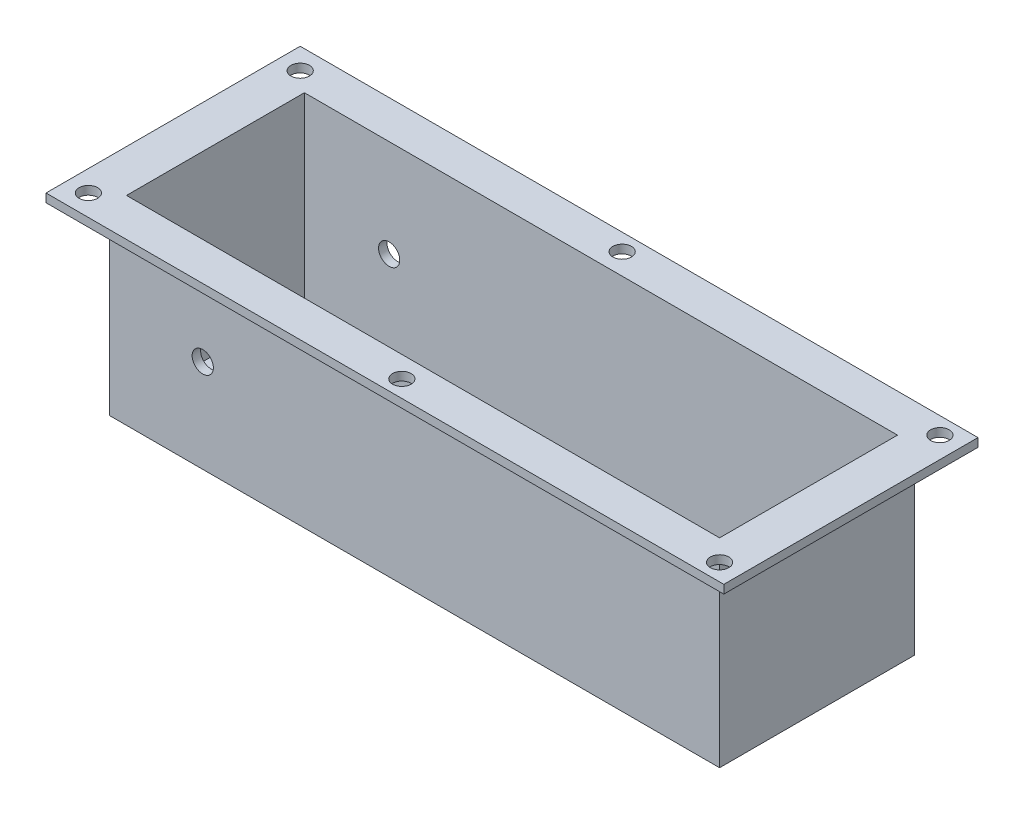
from build123d import *

# Parameters (mm, degrees)
SKETCH3_W           = 182.88
SKETCH3_H           = 58.42
BOSS_EXTRUDE1_DEPTH = 57.15
SKETCH4_W           = 203.2
SKETCH4_H           = 76.2
BOSS_EXTRUDE2_DEPTH = 2.54
SKETCH5_W           = 177.8
SKETCH5_H           = 53.34
CUT_EXTRUDE1_DEPTH  = 54.61
SKETCH6_R           = 2.7813
CUT_EXTRUDE2_DEPTH  = 53.34
SKETCH8_R           = 3.18135
CUT_EXTRUDE3_DEPTH  = 38.1


with BuildPart() as part:
    # Sketch3 → Boss-Extrude1 (new body)
    with BuildSketch(Plane(origin=(0, 0, 0), x_dir=(1, 0, 0), z_dir=(0, 1, 0))):
        Rectangle(SKETCH3_W, SKETCH3_H)
    extrude(amount=-BOSS_EXTRUDE1_DEPTH)

    # Sketch4 → Boss-Extrude2 (add)
    with BuildSketch(Plane(origin=(0, 0, 0), x_dir=(1, 0, 0), z_dir=(0, 1, 0))):
        Rectangle(SKETCH4_W, SKETCH4_H)
    extrude(amount=-BOSS_EXTRUDE2_DEPTH)

    # Sketch5 → Cut-Extrude1 (cut)
    with BuildSketch(Plane(origin=(0, 0, 0), x_dir=(1, 0, 0), z_dir=(0, 1, 0))):
        Rectangle(SKETCH5_W, SKETCH5_H)
    extrude(amount=-CUT_EXTRUDE1_DEPTH, mode=Mode.SUBTRACT)

    # Sketch6 → Cut-Extrude2 (cut)
    with BuildSketch(Plane(origin=(0, 0, 0), x_dir=(1, 0, 0), z_dir=(0, 1, 0))):
        with Locations((-95.25, 31.75)):
            Circle(SKETCH6_R)
        with Locations((0, 33.02)):
            Circle(SKETCH6_R)
        with Locations((95.25, 33.02)):
            Circle(SKETCH6_R)
        with Locations((95.25, -33.02)):
            Circle(SKETCH6_R)
        with Locations((0, -33.02)):
            Circle(SKETCH6_R)
        with Locations((-95.25, -31.75)):
            Circle(SKETCH6_R)
    extrude(amount=-CUT_EXTRUDE2_DEPTH, mode=Mode.SUBTRACT)

    # Sketch8 → Cut-Extrude3 (cut, symmetric)
    with BuildSketch(Plane.XY):
        with Locations((-63.5, -29.21)):
            Circle(SKETCH8_R)
    extrude(amount=CUT_EXTRUDE3_DEPTH, both=True, mode=Mode.SUBTRACT)


solid = part.part
